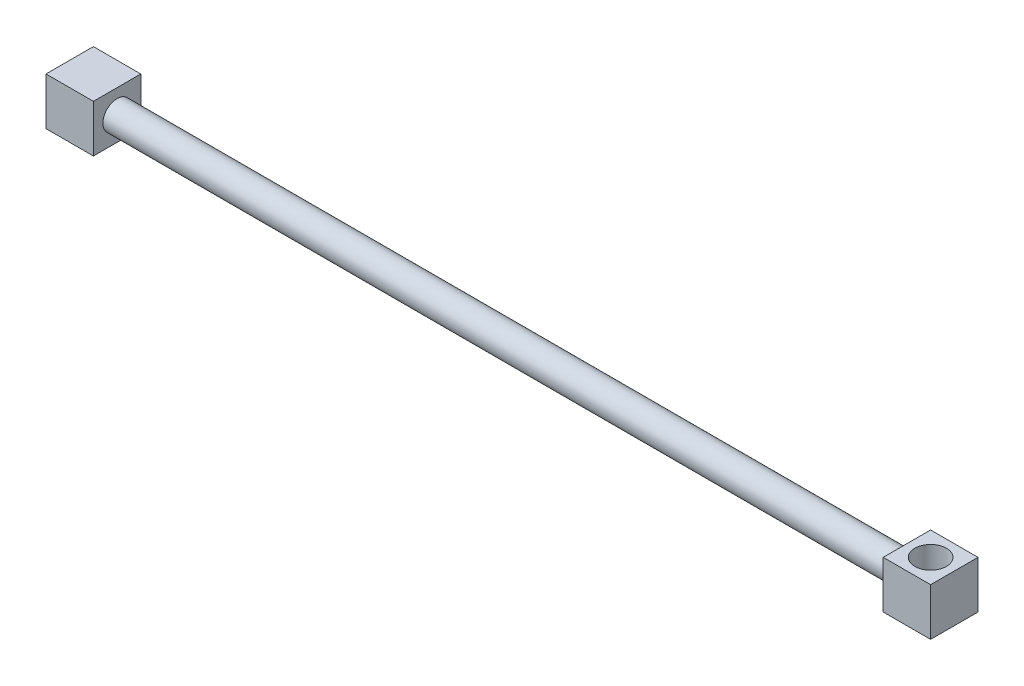
from build123d import *

# Parameters (mm, degrees)
SKETCH1_W           = 30
SKETCH1_H           = 30
BOSS_EXTRUDE1_DEPTH = 30
SKETCH2_R           = 9
BOSS_EXTRUDE2_DEPTH = 500
SKETCH3_W           = 30
SKETCH3_H           = 30
BOSS_EXTRUDE3_DEPTH = 30
SKETCH4_R           = 10
CUT_EXTRUDE1_DEPTH  = 30


with BuildPart() as part:
    # Sketch1 → Boss-Extrude1 (new body)
    with BuildSketch(Plane(origin=(0, 0, 0), x_dir=(0, 0, -1), z_dir=(1, 0, 0))):
        Rectangle(SKETCH1_W, SKETCH1_H)
    extrude(amount=BOSS_EXTRUDE1_DEPTH)

    # Sketch2 → Boss-Extrude2 (add)
    with BuildSketch(Plane(origin=(30, 0, 0), x_dir=(0, 0, -1), z_dir=(1, 0, 0))):
        Circle(SKETCH2_R)
    extrude(amount=BOSS_EXTRUDE2_DEPTH)

    # Sketch3 → Boss-Extrude3 (add)
    with BuildSketch(Plane(origin=(530, 0, 0), x_dir=(0, 0, -1), z_dir=(1, 0, 0))):
        Rectangle(SKETCH3_W, SKETCH3_H)
    extrude(amount=BOSS_EXTRUDE3_DEPTH)

    # Sketch4 → Cut-Extrude1 (cut)
    with BuildSketch(Plane(origin=(0, 15, 0), x_dir=(1, 0, 0), z_dir=(0, 1, 0))):
        with Locations((545, 0)):
            Circle(SKETCH4_R)
    extrude(amount=-CUT_EXTRUDE1_DEPTH, mode=Mode.SUBTRACT)


solid = part.part
